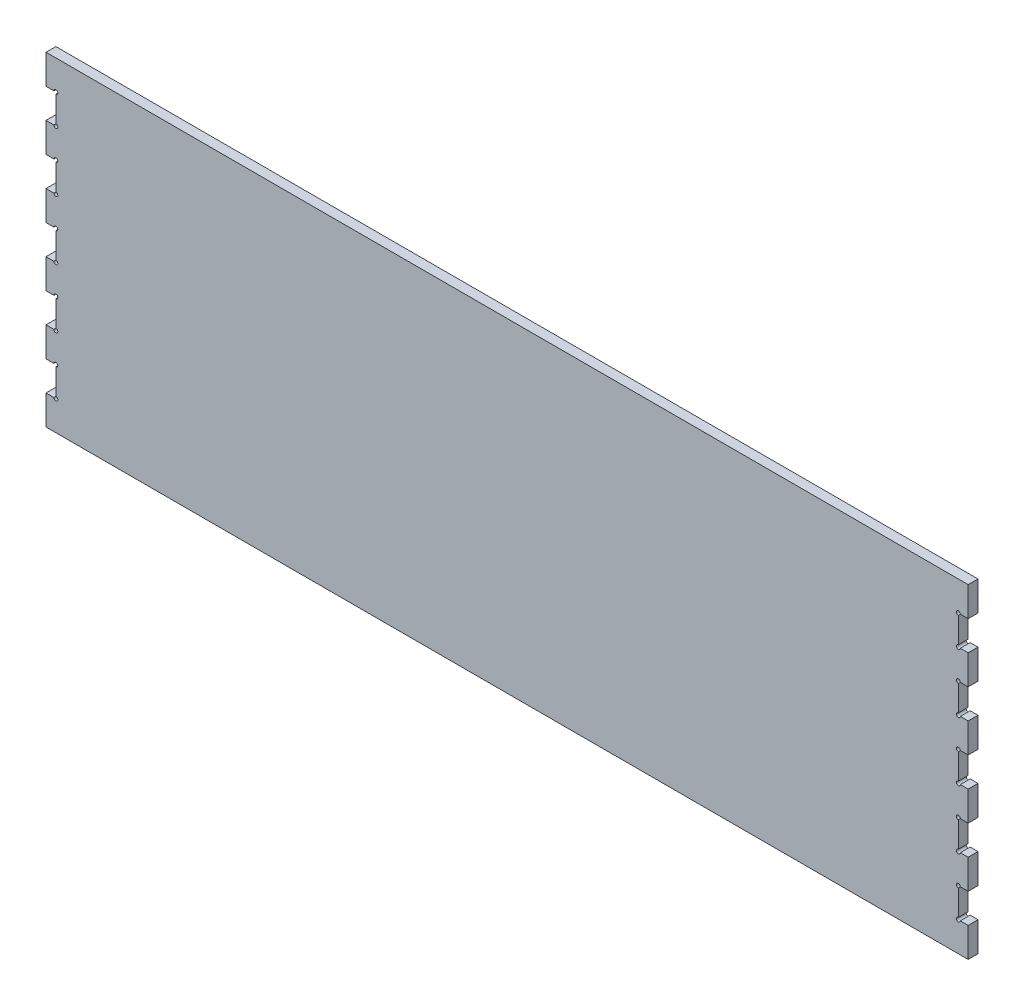
from build123d import *

# Parameters (mm, degrees)
BOSS_EXTRUDE1_DEPTH = 12


with BuildPart() as part:
    # Sketch1 → Boss-Extrude1 (new body)
    with BuildSketch(Plane.XY):
        with BuildLine():
            Line((562.664353911, 109.833333333), (553.064353911, 109.833333333))
            ThreePointArc((553.064353911, 109.833333333), (548.967297637, 111.530389608), (550.664353911, 107.433333333))
            Line((550.664353911, 107.433333333), (550.664353911, 76.233333333))
            ThreePointArc((550.664353911, 76.233333333), (548.967297637, 72.136277058), (553.064353911, 73.833333333))
            Line((553.064353911, 73.833333333), (562.664353911, 73.833333333))
            Line((562.664353911, 73.833333333), (562.664353911, 37.833333333))
            Line((562.664353911, 37.833333333), (553.064353911, 37.833333333))
            ThreePointArc((553.064353911, 37.833333333), (548.967297637, 39.530389608), (550.664353911, 35.433333333))
            Line((550.664353911, 35.433333333), (550.664353911, 4.233333333))
            ThreePointArc((550.664353911, 4.233333333), (548.967297637, 0.136277058), (553.064353911, 1.833333333))
            Line((553.064353911, 1.833333333), (562.664353911, 1.833333333))
            Line((562.664353911, 1.833333333), (562.664353911, -34.166666667))
            Line((562.664353911, -34.166666667), (553.064353911, -34.166666667))
            ThreePointArc((553.064353911, -34.166666667), (548.967297637, -32.469610392), (550.664353911, -36.566666667))
            Line((550.664353911, -36.566666667), (550.664353911, -67.766666667))
            ThreePointArc((550.664353911, -67.766666667), (548.967297637, -71.863722942), (553.064353911, -70.166666667))
            Line((553.064353911, -70.166666667), (562.664353911, -70.166666667))
            Line((562.664353911, -70.166666667), (562.664353911, -106.166666667))
            Line((562.664353911, -106.166666667), (553.064353911, -106.166666667))
            ThreePointArc((553.064353911, -106.166666667), (548.967297637, -104.469610392), (550.664353911, -108.566666667))
            Line((550.664353911, -108.566666667), (550.664353911, -139.766666667))
            ThreePointArc((550.664353911, -139.766666667), (548.967297637, -143.863722942), (553.064353911, -142.166666667))
            Line((553.064353911, -142.166666667), (562.664353911, -142.166666667))
            Line((562.664353911, -142.166666667), (562.664353911, -178.166666667))
            Line((562.664353911, -178.166666667), (553.064353911, -178.166666667))
            ThreePointArc((553.064353911, -178.166666667), (548.967297637, -176.469610392), (550.664353911, -180.566666667))
            Line((550.664353911, -180.566666667), (550.664353911, -211.766666667))
            ThreePointArc((550.664353911, -211.766666667), (548.967297637, -215.863722942), (553.064353911, -214.166666667))
            Line((553.064353911, -214.166666667), (562.664353911, -214.166666667))
            Line((562.664353911, -214.166666667), (562.664353911, -250.166666667))
            Line((562.664353911, -250.166666667), (-562.335646089, -250.166666667))
            Line((-562.335646089, -250.166666667), (-562.335646089, -214.166666667))
            Line((-562.335646089, -214.166666667), (-552.735646089, -214.166666667))
            ThreePointArc((-552.735646089, -214.166666667), (-548.638589814, -215.863722942), (-550.335646089, -211.766666667))
            Line((-550.335646089, -211.766666667), (-550.335646089, -180.566666667))
            ThreePointArc((-550.335646089, -180.566666667), (-548.638589814, -176.469610392), (-552.735646089, -178.166666667))
            Line((-552.735646089, -178.166666667), (-562.335646089, -178.166666667))
            Line((-562.335646089, -178.166666667), (-562.335646089, -142.166666667))
            Line((-562.335646089, -142.166666667), (-552.735646089, -142.166666667))
            ThreePointArc((-552.735646089, -142.166666667), (-548.638589814, -143.863722942), (-550.335646089, -139.766666667))
            Line((-550.335646089, -139.766666667), (-550.335646089, -108.566666667))
            ThreePointArc((-550.335646089, -108.566666667), (-548.638589814, -104.469610392), (-552.735646089, -106.166666667))
            Line((-552.735646089, -106.166666667), (-562.335646089, -106.166666667))
            Line((-562.335646089, -106.166666667), (-562.335646089, -70.166666667))
            Line((-562.335646089, -70.166666667), (-552.735646089, -70.166666667))
            ThreePointArc((-552.735646089, -70.166666667), (-548.638589814, -71.863722942), (-550.335646089, -67.766666667))
            Line((-550.335646089, -67.766666667), (-550.335646089, -36.566666667))
            ThreePointArc((-550.335646089, -36.566666667), (-548.638589814, -32.469610392), (-552.735646089, -34.166666667))
            Line((-552.735646089, -34.166666667), (-562.335646089, -34.166666667))
            Line((-562.335646089, -34.166666667), (-562.335646089, 1.833333333))
            Line((-562.335646089, 1.833333333), (-552.735646089, 1.833333333))
            ThreePointArc((-552.735646089, 1.833333333), (-548.638589814, 0.136277058), (-550.335646089, 4.233333333))
            Line((-550.335646089, 4.233333333), (-550.335646089, 35.433333333))
            ThreePointArc((-550.335646089, 35.433333333), (-548.638589814, 39.530389608), (-552.735646089, 37.833333333))
            Line((-552.735646089, 37.833333333), (-562.335646089, 37.833333333))
            Line((-562.335646089, 37.833333333), (-562.335646089, 73.833333333))
            Line((-562.335646089, 73.833333333), (-552.735646089, 73.833333333))
            ThreePointArc((-552.735646089, 73.833333333), (-548.638589814, 72.136277058), (-550.335646089, 76.233333333))
            Line((-550.335646089, 76.233333333), (-550.335646089, 107.433333333))
            ThreePointArc((-550.335646089, 107.433333333), (-548.638589814, 111.530389608), (-552.735646089, 109.833333333))
            Line((-552.735646089, 109.833333333), (-562.335646089, 109.833333333))
            Line((-562.335646089, 109.833333333), (-562.335646089, 145.833333333))
            Line((-562.335646089, 145.833333333), (562.664353911, 145.833333333))
            Line((562.664353911, 145.833333333), (562.664353911, 109.833333333))
        make_face()
    extrude(amount=BOSS_EXTRUDE1_DEPTH)


solid = part.part
